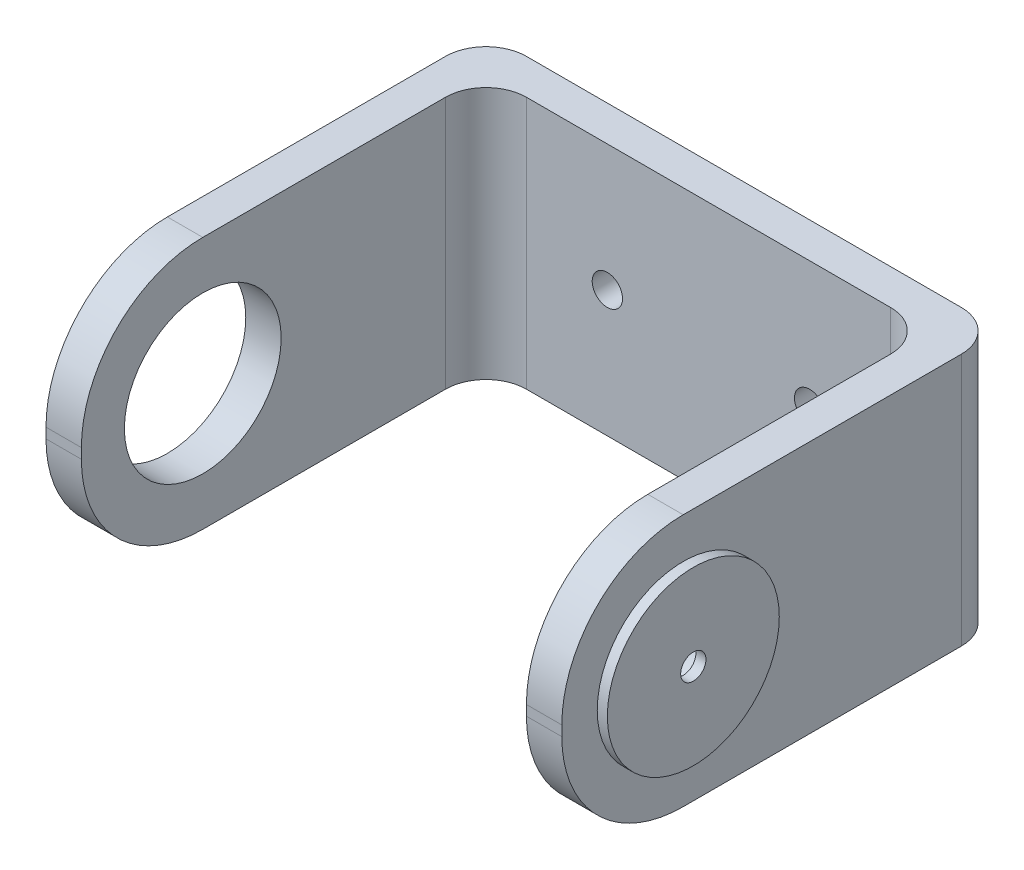
from build123d import *

# Parameters (mm, degrees)
SALIENTE_EXTRUIR1_DEPTH = 25
REDONDEO1_R             = 12
CROQUIS2_R              = 7.75
CORTAR_EXTRUIR1_DEPTH   = 10
CROQUIS3_R              = 2.8
CORTAR_EXTRUIR2_DEPTH   = 10
CROQUIS4_R              = 8.5
SALIENTE_EXTRUIR3_DEPTH = 1
CROQUIS5_R              = 1.25
CORTAR_EXTRUIR3_DEPTH   = 1
REDONDEO2_R             = 4
REDONDEO3_R             = 4
CROQUIS6_R              = 1.5
CORTAR_EXTRUIR4_DEPTH   = 10


with BuildPart() as part:
    # Croquis1 → Saliente-Extruir1 (new body)
    with BuildSketch(Plane(origin=(0, 0, 0), x_dir=(1, 0, 0), z_dir=(0, 1, 0))):
        Polygon((-25.5, -40), (-22, -40), (-22, 0), (22, 0), (22, -40), (25.5, -40), (25.5, 3.5), (-25.5, 3.5), align=None)
    extrude(amount=SALIENTE_EXTRUIR1_DEPTH)

    # Redondeo1
    redondeo1_edges = [part.edges().sort_by_distance(p)[0] for p in [
        (23.75, 0, 40),
        (-23.75, 0, 40),
        (23.75, 25, 40),
        (-23.75, 25, 40),
    ]]
    fillet(redondeo1_edges, radius=REDONDEO1_R)

    # Croquis2 → Cortar-Extruir1 (cut)
    with BuildSketch(Plane.ZY.offset(25.5)):
        with Locations((28, 12.5)):
            Circle(CROQUIS2_R)
    extrude(amount=-CORTAR_EXTRUIR1_DEPTH, mode=Mode.SUBTRACT)

    # Croquis3 → Cortar-Extruir2 (cut)
    with BuildSketch(Plane(origin=(25.5, 0, 0), x_dir=(0, 0, -1), z_dir=(1, 0, 0))):
        with Locations((-28, 12.5)):
            Circle(CROQUIS3_R)
    extrude(amount=-CORTAR_EXTRUIR2_DEPTH, mode=Mode.SUBTRACT)

    # Croquis4 → Saliente-Extruir3 (add)
    with BuildSketch(Plane(origin=(25.5, 0, 0), x_dir=(0, 0, -1), z_dir=(1, 0, 0))):
        with Locations((-28, 12.5)):
            Circle(CROQUIS4_R)
    extrude(amount=SALIENTE_EXTRUIR3_DEPTH)

    # Croquis5 → Cortar-Extruir3 (cut)
    with BuildSketch(Plane(origin=(26.5, 0, 0), x_dir=(0, 0, -1), z_dir=(1, 0, 0))):
        with Locations((-28, 12.5)):
            Circle(CROQUIS5_R)
    extrude(amount=-CORTAR_EXTRUIR3_DEPTH, mode=Mode.SUBTRACT)

    # Redondeo2
    redondeo2_edges = [part.edges().sort_by_distance(p)[0] for p in [
        (22, 12.5, 0),
        (-22, 12.5, 0),
    ]]
    fillet(redondeo2_edges, radius=REDONDEO2_R)

    # Redondeo3
    redondeo3_edges = [part.edges().sort_by_distance(p)[0] for p in [
        (-25.5, 12.5, -3.5),
        (25.5, 12.5, -3.5),
    ]]
    fillet(redondeo3_edges, radius=REDONDEO3_R)

    # Croquis6 → Cortar-Extruir4 (cut)
    with BuildSketch(Plane(origin=(0, 0, -3.5), x_dir=(-1, 0, 0), z_dir=(0, 0, -1))):
        with Locations((-10, 12.5)):
            Circle(CROQUIS6_R)
        with Locations((10, 12.5)):
            Circle(CROQUIS6_R)
    extrude(amount=-CORTAR_EXTRUIR4_DEPTH, mode=Mode.SUBTRACT)


solid = part.part
